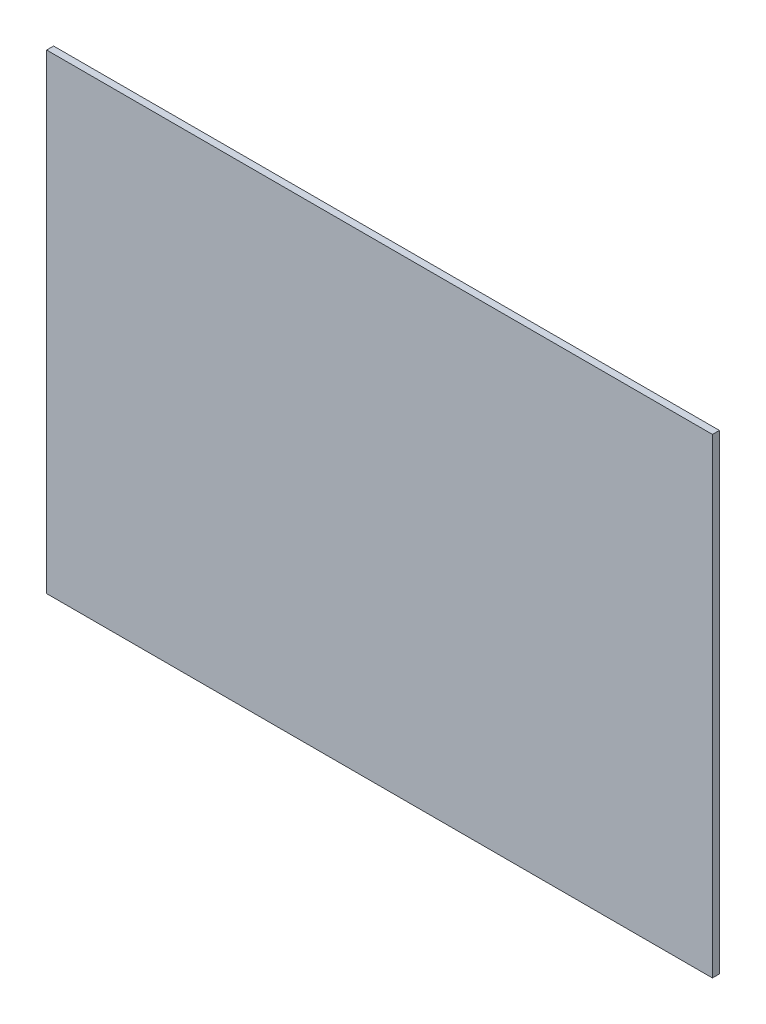
from build123d import *

# Parameters (mm, degrees)
SKETCH1_W           = 297
SKETCH1_H           = 210
BOSS_EXTRUDE1_DEPTH = 3.1


with BuildPart() as part:
    # Sketch1 → Boss-Extrude1 (new body)
    with BuildSketch(Plane.XY):
        Rectangle(SKETCH1_W, SKETCH1_H)
    extrude(amount=BOSS_EXTRUDE1_DEPTH)


solid = part.part
